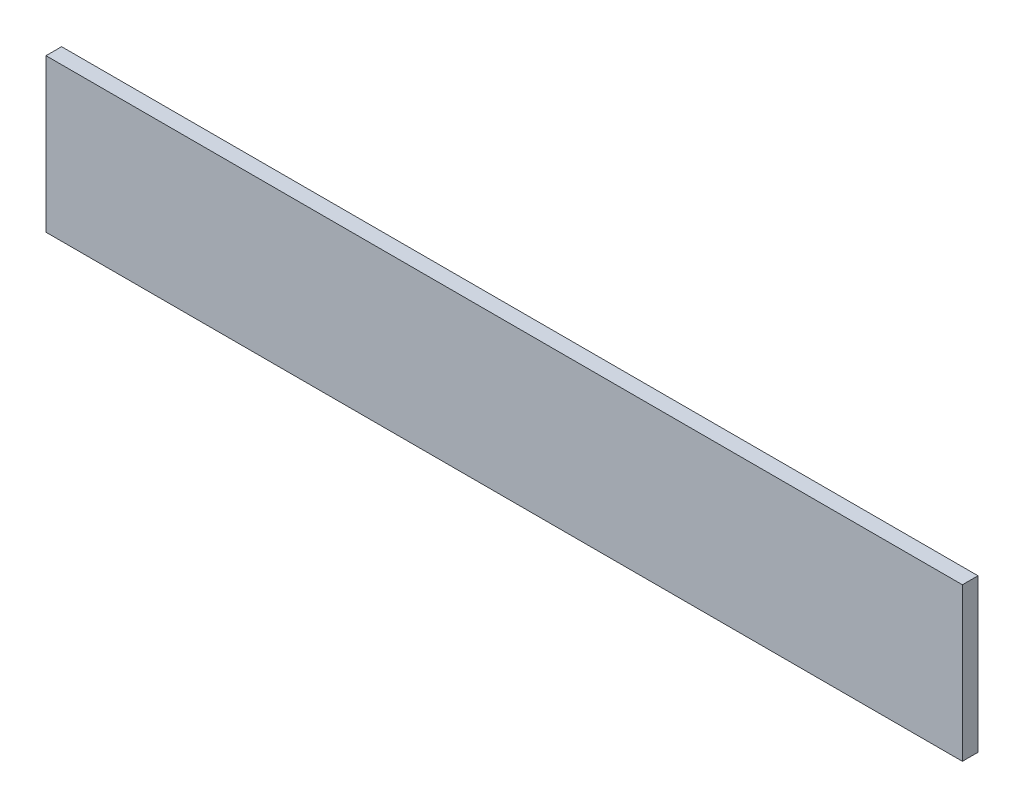
from build123d import *

# Parameters (mm, degrees)
SKETCH_1_W      = 176.06
SKETCH_1_H      = 29.38
EXTRUDE_1_DEPTH = 3


with BuildPart() as part:
    # 草图1 → 凸台-拉伸1 (new body)
    with BuildSketch(Plane.XY):
        Rectangle(SKETCH_1_W, SKETCH_1_H)
    extrude(amount=EXTRUDE_1_DEPTH)


solid = part.part
